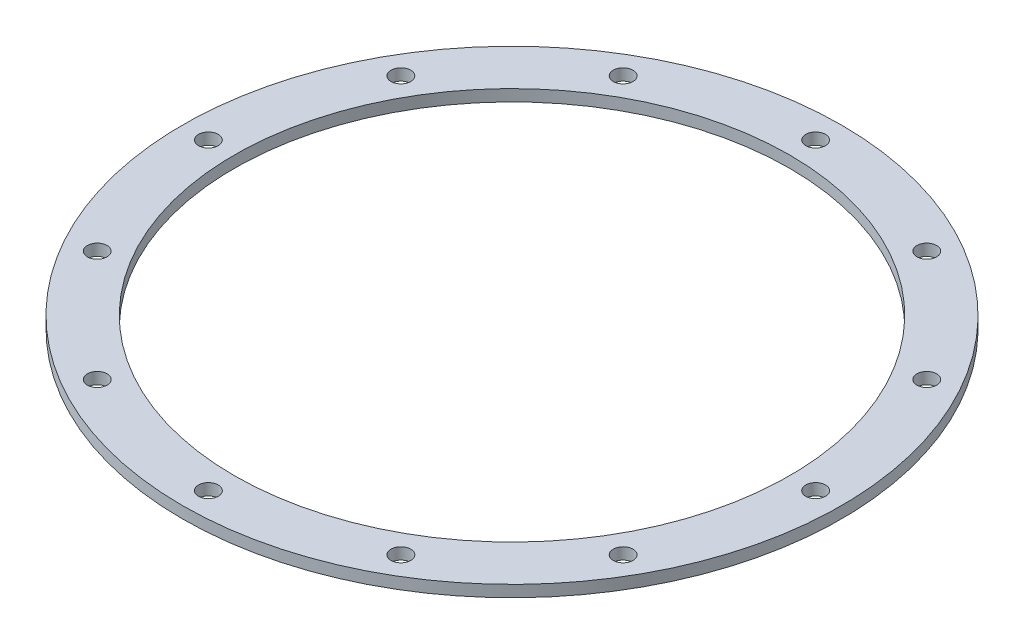
from build123d import *

# Parameters (mm, degrees)
SKETCH1_W                    = 7.112
SKETCH1_H                    = 1.5875
F_36_0_1065_DIAMETER_HOLE1_D = 2.7051
SCREW_PASSTHROUGHS_COUNT     = 12


with BuildPart() as part:
    # Sketch1 → Main (revolve)
    with BuildSketch(Plane.XY):
        with Locations((-41.656, 0.79375)):
            Rectangle(SKETCH1_W, SKETCH1_H)
    revolve(axis=Axis((0, 55, 0), (0, -1, 0)))

    # #36 (0.1065) Diameter Hole1 (through all)
    with Locations(Plane(origin=(0, 0, 0), x_dir=(-1, 0, 0), z_dir=(0, -1, 0))):
        with Locations((41.656, 0)):
            f_36_0_1065_diameter_hole1 = Hole(F_36_0_1065_DIAMETER_HOLE1_D / 2)

    # Screw Passthroughs: #36 (0.1065) Diameter Hole1 ×12 about axis
    screw_passthroughs_axis = Axis((0, 0, 0), (0, 1, 0))
    for i in range(1, SCREW_PASSTHROUGHS_COUNT):
        add(f_36_0_1065_diameter_hole1.rotate(screw_passthroughs_axis, i * 360 / SCREW_PASSTHROUGHS_COUNT), mode=Mode.SUBTRACT)


solid = part.part
